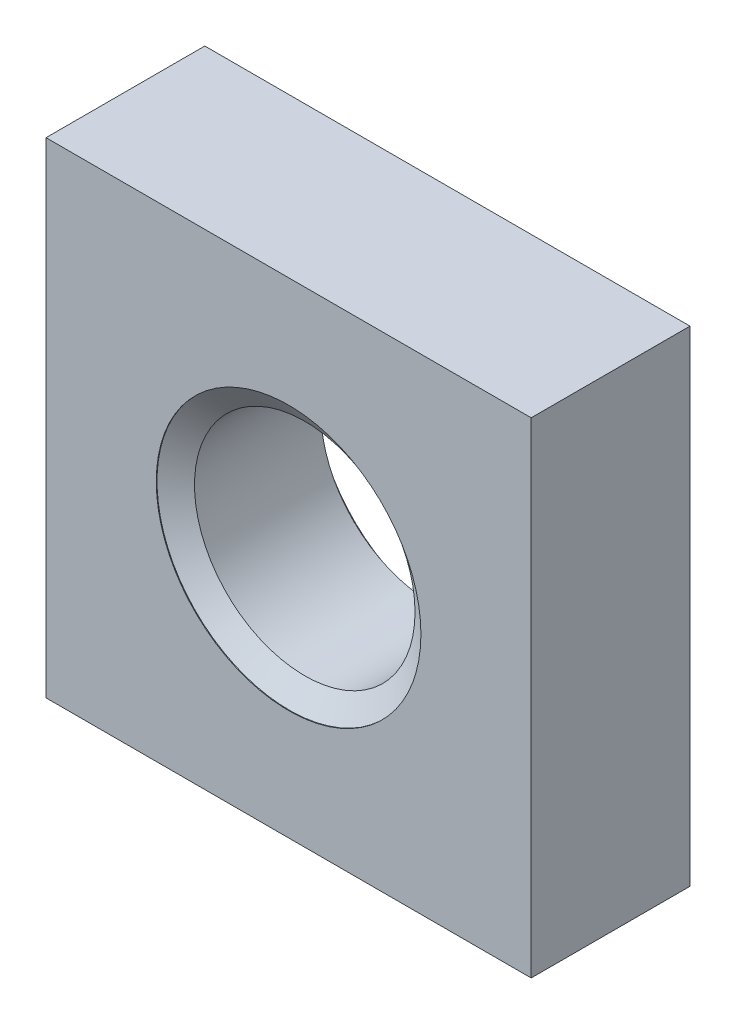
from build123d import *

# Parameters (mm, degrees)
BASENUT_START = -1.8
BASENUTSKE_W  = 5.5
BASENUTSKE_H  = 5.5
BASENUTSKE_R  = 1.25
BASENUT_DEPTH = 1.8


with BuildPart() as part:
    # BaseNutSke → BaseNut (new body)
    with BuildSketch(Plane.XY.offset(BASENUT_START)):
        Rectangle(BASENUTSKE_W, BASENUTSKE_H)
        Circle(BASENUTSKE_R, mode=Mode.SUBTRACT)
    extrude(amount=BASENUT_DEPTH)

    # EndChamferSketch → EndChamfer (revolve, cut)
    with BuildSketch(Plane(origin=(0, 0, 0), x_dir=(0, 0, -1), z_dir=(1, 0, 0))):
        Polygon((1.791, 1.5), (1.598442927, 1.225), (1.801, 1.225), (1.801, 1.5), align=None)
        Polygon((-0.002, 1.5), (0.008, 1.5), (0.200557073, 1.225), (-0.002, 1.225), align=None)
    revolve(axis=Axis((0, 0, -25.037505729), (0, 0, -1)), mode=Mode.SUBTRACT)


solid = part.part
